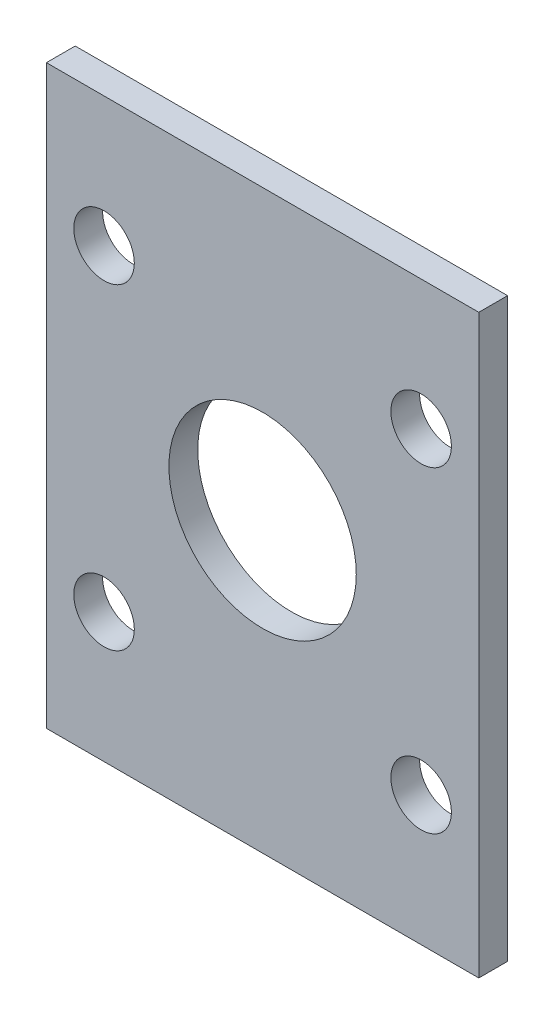
from build123d import *

# Parameters (mm, degrees)
EXTRUDE_1_DEPTH     = 2
SKETCH_2_R          = 6.5
CUT_EXTRUDE_1_DEPTH = 2
SKETCH_5_W          = 30
SKETCH_5_H          = 2
EXTRUDE_4_DEPTH     = 5
SKETCH_6_W          = 30
SKETCH_6_H          = 2
EXTRUDE_5_DEPTH     = 5


with BuildPart() as part:
    # ｽｹｯﾁ1 → ﾎﾞｽ - 押し出し1 (new body)
    with BuildSketch(Plane.XY):
        with BuildLine():
            Line((11, 15), (-11, 15))
            Line((-11, 15), (-11, 13.1))
            ThreePointArc((-11, 13.1), (-9.51507576, 12.48492424), (-8.9, 11))
            ThreePointArc((-8.9, 11), (-11, 8.9), (-13.1, 11))
            Line((-13.1, 11), (-15, 11))
            Line((-15, 11), (-15, -11))
            Line((-15, -11), (-13.1, -11))
            ThreePointArc((-13.1, -11), (-11, -8.9), (-8.9, -11))
            ThreePointArc((-8.9, -11), (-9.51507576, -12.48492424), (-11, -13.1))
            Line((-11, -13.1), (-11, -15))
            Line((-11, -15), (11, -15))
            Line((11, -15), (11, -13.1))
            ThreePointArc((11, -13.1), (9.51507576, -9.51507576), (13.1, -11))
            Line((13.1, -11), (15, -11))
            Line((15, -11), (15, 11))
            Line((15, 11), (13.1, 11))
            ThreePointArc((13.1, 11), (9.51507576, 9.51507576), (11, 13.1))
            Line((11, 13.1), (11, 15))
        make_face()
        with BuildLine():
            Line((15, -15), (15, -11))
            Line((15, -11), (13.1, -11))
            ThreePointArc((13.1, -11), (12.48492424, -12.48492424), (11, -13.1))
            Line((11, -13.1), (11, -15))
            Line((11, -15), (15, -15))
        make_face()
        with BuildLine():
            Line((-13.1, -11), (-15, -11))
            Line((-15, -11), (-15, -15))
            Line((-15, -15), (-11, -15))
            Line((-11, -15), (-11, -13.1))
            ThreePointArc((-11, -13.1), (-12.48492424, -12.48492424), (-13.1, -11))
        make_face()
        with BuildLine():
            Line((-11, 15), (-15, 15))
            Line((-15, 15), (-15, 11))
            Line((-15, 11), (-13.1, 11))
            ThreePointArc((-13.1, 11), (-12.48492424, 12.48492424), (-11, 13.1))
            Line((-11, 13.1), (-11, 15))
        make_face()
        with BuildLine():
            Line((15, 15), (11, 15))
            Line((11, 15), (11, 13.1))
            ThreePointArc((11, 13.1), (12.48492424, 12.48492424), (13.1, 11))
            Line((13.1, 11), (15, 11))
            Line((15, 11), (15, 15))
        make_face()
    extrude(amount=EXTRUDE_1_DEPTH)

    # ｽｹｯﾁ2 → ｶｯﾄ - 押し出し1 (cut)
    with BuildSketch(Plane.XY.offset(2)):
        Circle(SKETCH_2_R)
    extrude(amount=-CUT_EXTRUDE_1_DEPTH, mode=Mode.SUBTRACT)

    # ｽｹｯﾁ5 → ﾎﾞｽ - 押し出し4 (add)
    with BuildSketch(Plane(origin=(0, 15, 0), x_dir=(1, 0, 0), z_dir=(0, 1, 0))):
        with Locations((0, -1)):
            Rectangle(SKETCH_5_W, SKETCH_5_H)
    extrude(amount=EXTRUDE_4_DEPTH)

    # ｽｹｯﾁ6 → ﾎﾞｽ - 押し出し5 (add)
    with BuildSketch(Plane(origin=(0, -15, 0), x_dir=(-1, 0, 0), z_dir=(0, -1, 0))):
        with Locations((0, -1)):
            Rectangle(SKETCH_6_W, SKETCH_6_H)
    extrude(amount=EXTRUDE_5_DEPTH)


solid = part.part
